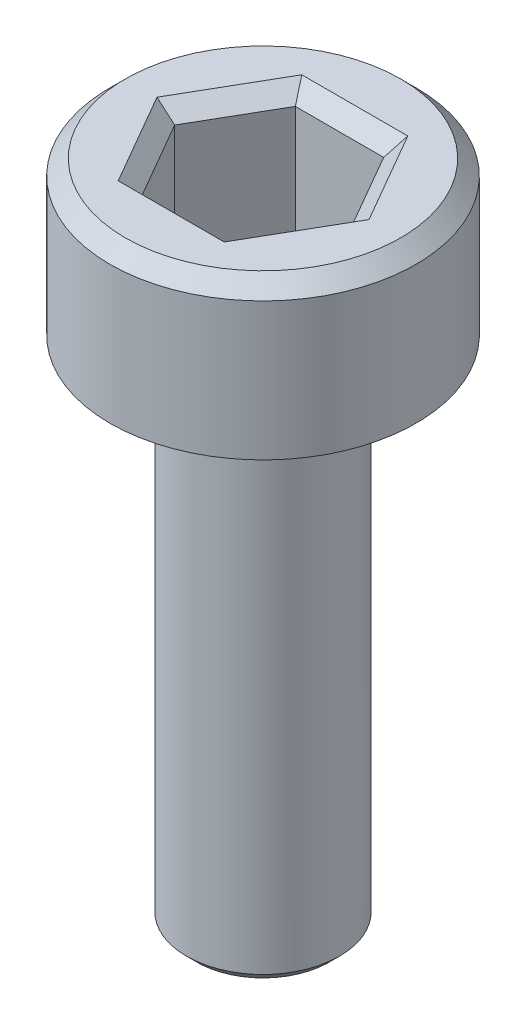
from build123d import *

# Parameters (mm, degrees)
SKETCH1_R           = 3
BOSS_EXTRUDE1_DEPTH = 3
CHAMFER1_SIZE       = 0.3
CUT_EXTRUDE1_DEPTH  = 2.5
CHAMFER2_SIZE       = 0.3
SKETCH3_R           = 1.5
BOSS_EXTRUDE2_DEPTH = 10
CHAMFER3_SIZE       = 0.2


with BuildPart() as part:
    # Sketch1 → Boss-Extrude1 (new body)
    with BuildSketch(Plane(origin=(0, 0, 0), x_dir=(1, 0, 0), z_dir=(0, 1, 0))):
        with Locations(Location((0, 0, 0), (0, 0, 270))):  # turned: the seam where the file's is
            Circle(SKETCH1_R)
    extrude(amount=BOSS_EXTRUDE1_DEPTH)

    # Chamfer1
    chamfer1_edges = [part.edges().sort_by_distance(p)[0] for p in [
        (0, 3, -3),
    ]]
    chamfer(chamfer1_edges, length=CHAMFER1_SIZE)

    # Sketch2 → Cut-Extrude1 (cut)
    with BuildSketch(Plane(origin=(0, 3, 0), x_dir=(1, 0, 0), z_dir=(0, 1, 0))):
        Polygon((1.732050808, 0), (0.866025404, 1.5), (-0.866025404, 1.5), (-1.732050808, 0), (-0.866025404, -1.5), (0.866025404, -1.5), align=None)
    extrude(amount=-CUT_EXTRUDE1_DEPTH, mode=Mode.SUBTRACT)

    # Chamfer2
    chamfer2_edges = [part.edges().sort_by_distance(p)[0] for p in [
        (1.299038106, 3, 0.75),
        (1.299038106, 3, -0.75),
        (0, 3, -1.5),
        (-1.299038106, 3, -0.75),
        (-1.299038106, 3, 0.75),
        (0, 3, 1.5),
    ]]
    chamfer(chamfer2_edges, length=CHAMFER2_SIZE)

    # Sketch3 → Boss-Extrude2 (add)
    with BuildSketch(Plane.XZ):
        with Locations(Location((0, 0, 0), (0, 0, 90))):  # turned: the seam where the file's is
            Circle(SKETCH3_R)
    extrude(amount=BOSS_EXTRUDE2_DEPTH)

    # Chamfer3
    chamfer3_edges = [part.edges().sort_by_distance(p)[0] for p in [
        (0, -10, -1.5),
    ]]
    chamfer(chamfer3_edges, length=CHAMFER3_SIZE)


solid = part.part
